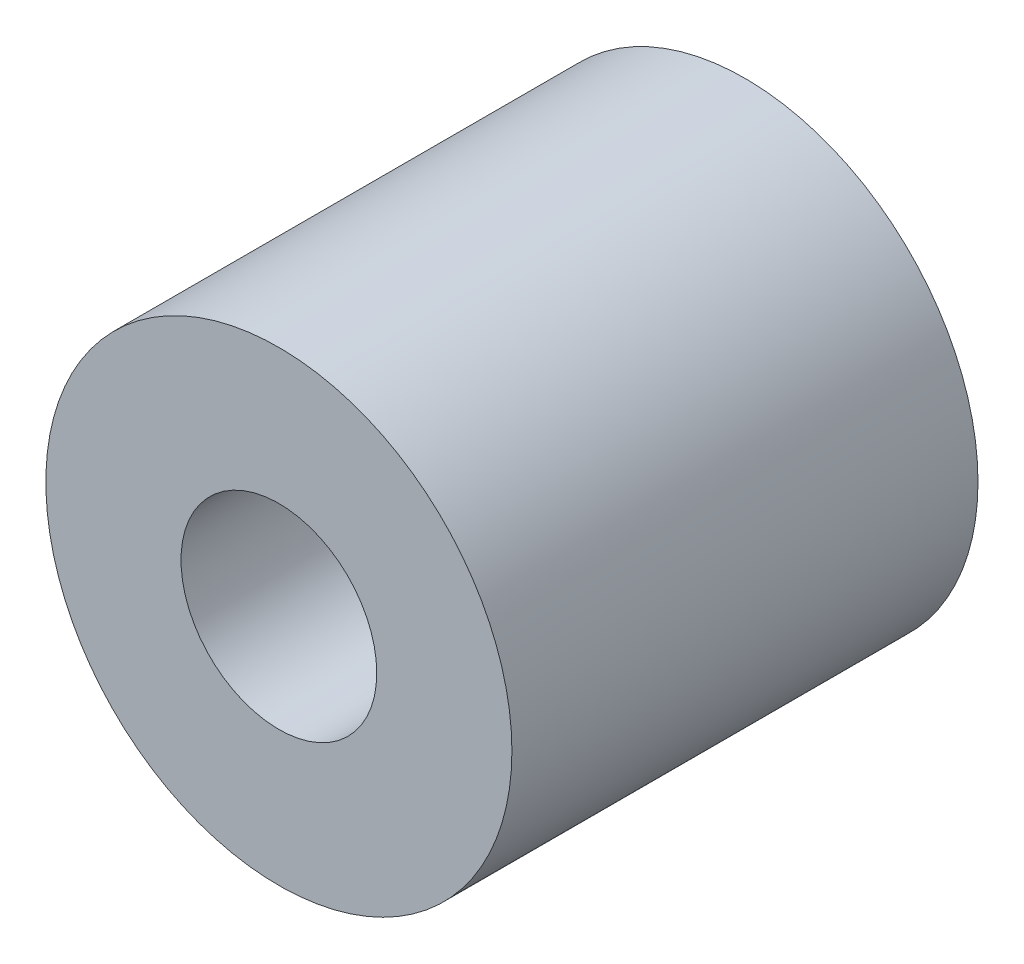
from build123d import *

# Parameters (mm, degrees)
SKETCH_1_R      = 5
SKETCH_1_R_2    = 2.1
EXTRUDE_1_DEPTH = 10


with BuildPart() as part:
    # ｽｹｯﾁ1 → ﾎﾞｽ - 押し出し1 (new body)
    with BuildSketch(Plane.XY):
        Circle(SKETCH_1_R)
        Circle(SKETCH_1_R_2, mode=Mode.SUBTRACT)
    extrude(amount=EXTRUDE_1_DEPTH)


solid = part.part
